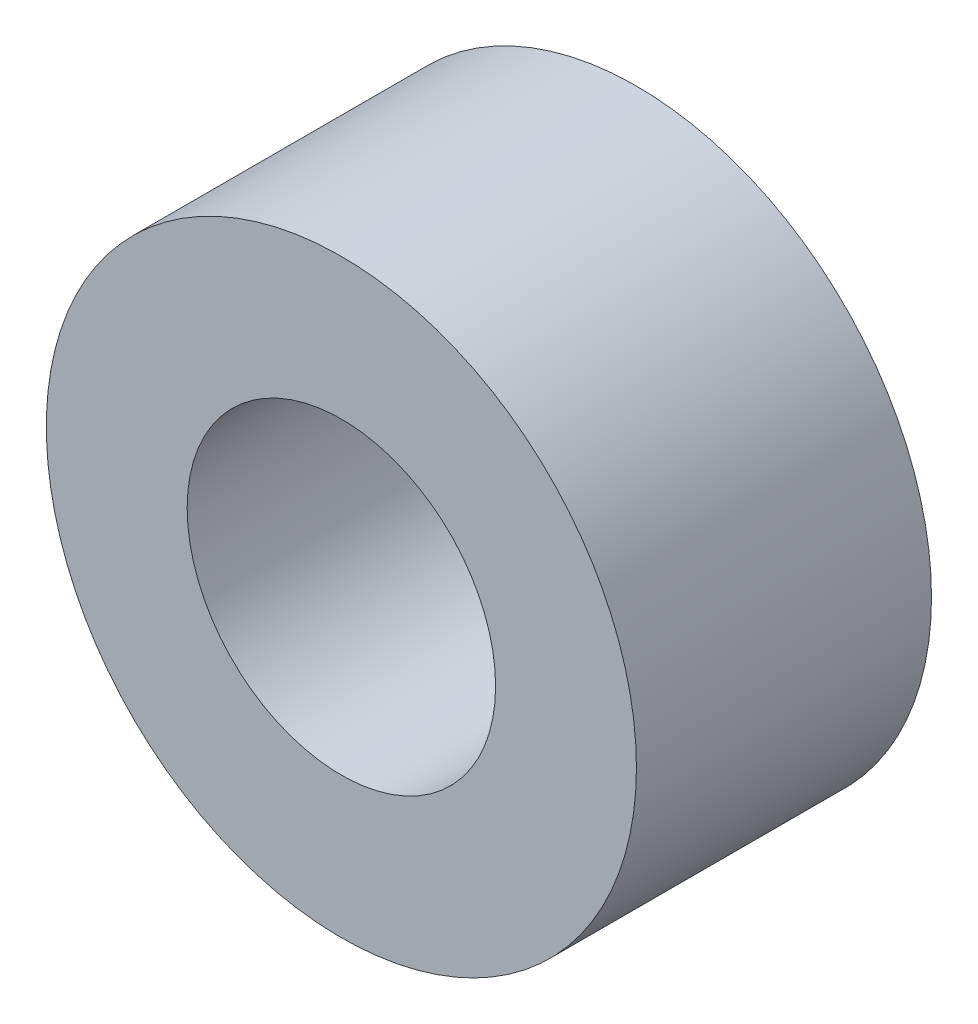
from build123d import *

# Parameters (mm, degrees)
SKETCH1_R           = 4.7625
SKETCH1_R_2         = 2.4892
BOSS_EXTRUDE1_DEPTH = 4.7625


with BuildPart() as part:
    # Sketch1 → Boss-Extrude1 (new body)
    with BuildSketch(Plane.XY):
        Circle(SKETCH1_R)
        Circle(SKETCH1_R_2, mode=Mode.SUBTRACT)
    extrude(amount=BOSS_EXTRUDE1_DEPTH)


solid = part.part
